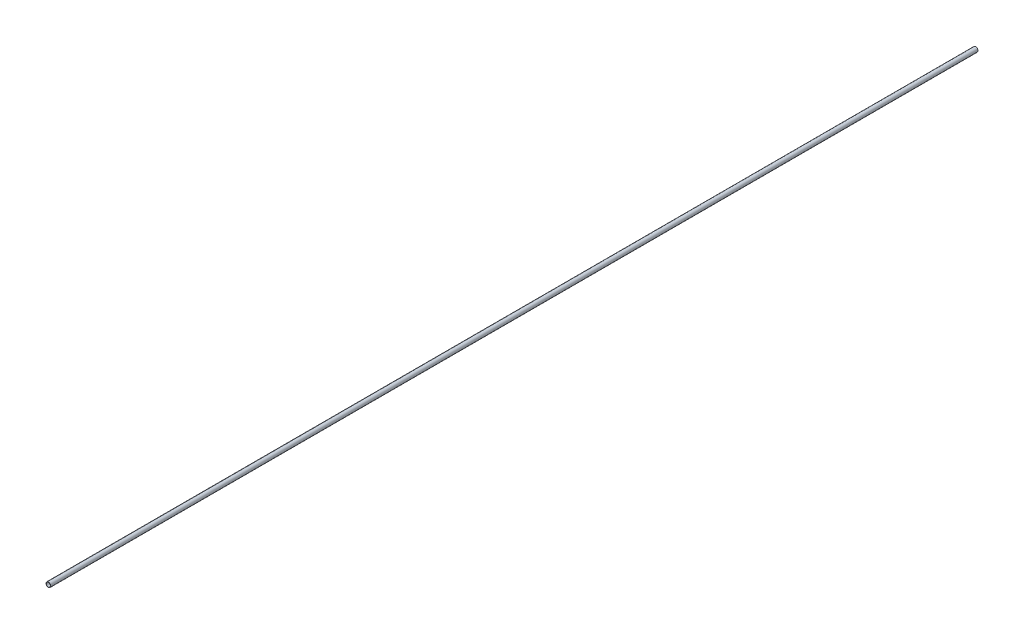
from build123d import *

# Parameters (mm, degrees)
SKETCH1_R           = 2.53
SKETCH1_R_2         = 2.23
EXTRUDE_THIN1_DEPTH = 1000


with BuildPart() as part:
    # Sketch1 → Extrude-Thin1 (new body)
    with BuildSketch(Plane.XY):
        Circle(SKETCH1_R)
        Circle(SKETCH1_R_2, mode=Mode.SUBTRACT)
    extrude(amount=EXTRUDE_THIN1_DEPTH)


solid = part.part
